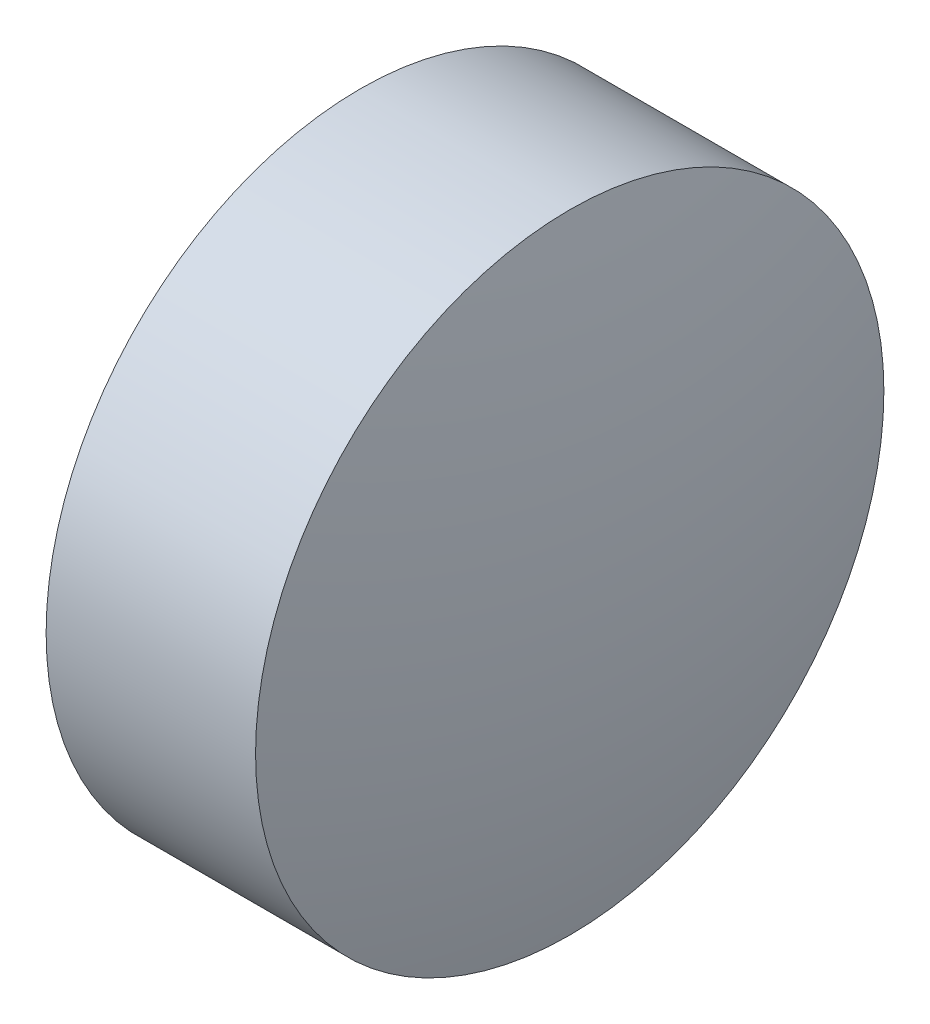
from build123d import *

# Parameters (mm, degrees)
SKETCH_2_ONE_SIDE_W = 1
SKETCH_2_ONE_SIDE_H = 1.500008572


with BuildPart() as part:
    # 草图2 one side → 旋转1 (revolve)
    with BuildSketch(Plane.XY):
        with Locations((10.211656042, 6.492097691)):
            Rectangle(SKETCH_2_ONE_SIDE_W, SKETCH_2_ONE_SIDE_H)
        with BuildLine():
            Line((9.5317493, 5.742093405), (9.711656042, 5.742093405))
            Line((9.711656042, 5.742093405), (9.711656042, 7.242101977))
            ThreePointArc((9.711656042, 7.242101977), (9.576886579, 6.497472805), (9.5317493, 5.742093405))
        make_face()
        with BuildLine():
            Line((10.711656042, 5.742093405), (10.891562785, 5.742093405))
            ThreePointArc((10.891562785, 5.742093405), (10.846425505, 6.497472805), (10.711656042, 7.242101977))
            Line((10.711656042, 7.242101977), (10.711656042, 5.742093405))
        make_face()
    revolve(axis=Axis((9.287603356, 5.742093405, 0), (1, 0, 0)))


solid = part.part
